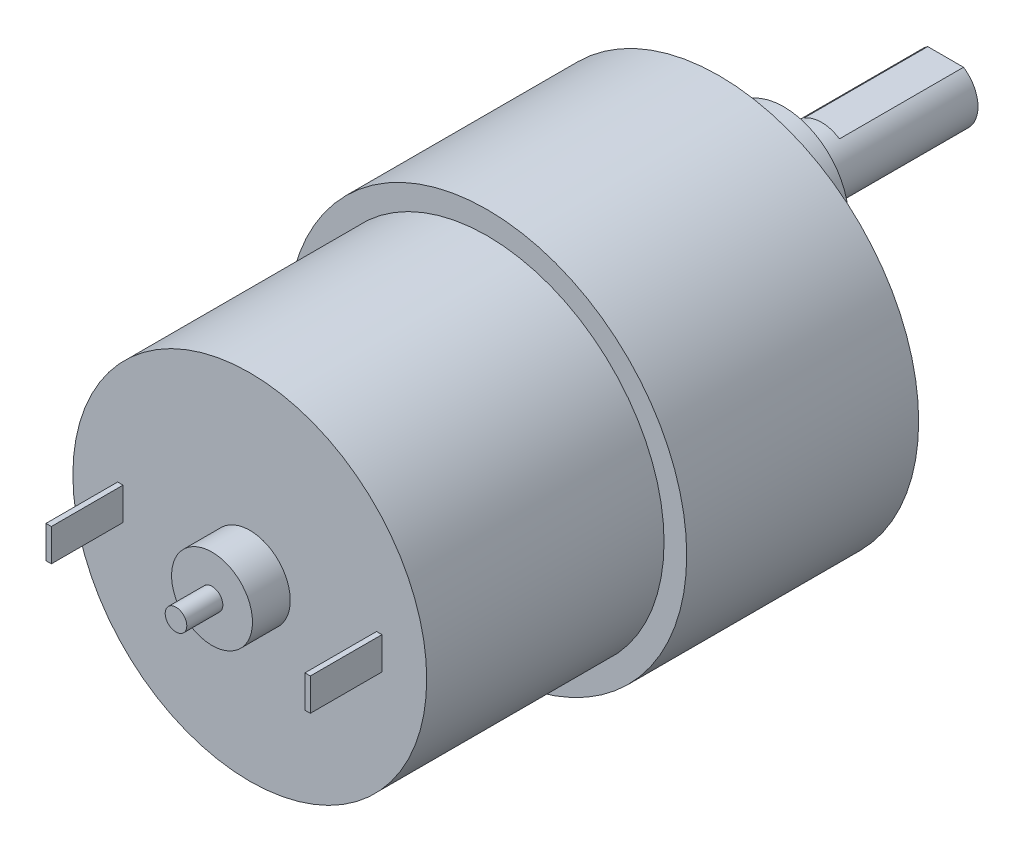
from build123d import *

# Parameters (mm, degrees)
SKETCH_1_R               = 18.5
EXTRUDE_1_DEPTH          = 21.5
SKETCH_2_R               = 6
EXTRUDE_2_DEPTH          = 6
SKETCH_3_R               = 3
EXTRUDE_3_DEPTH          = 15
CUT_EXTRUDE_1_DEPTH      = 1
CUT_EXTRUDE_1_DEPTH_BACK = 11.5
SKETCH_5_R               = 1.5
CUT_EXTRUDE_2_DEPTH      = 5
SKETCH_6_R               = 16.4
EXTRUDE_4_DEPTH          = 22
SKETCH_7_R               = 1
EXTRUDE_5_DEPTH          = 6.84
SKETCH_8_R               = 3.75
EXTRUDE_6_DEPTH          = 3.5
SKETCH_9_W               = 0.5
SKETCH_9_H               = 3
EXTRUDE_7_DEPTH          = 6.64


with BuildPart() as part:
    # 草图1 → 凸台-拉伸1 (new body)
    with BuildSketch(Plane.XY):
        Circle(SKETCH_1_R)
    extrude(amount=EXTRUDE_1_DEPTH)

    # 草图2 → 凸台-拉伸2 (add)
    with BuildSketch(Plane(origin=(0, 0, 0), x_dir=(-1, 0, 0), z_dir=(0, 0, -1))):
        with Locations((0, 7)):
            Circle(SKETCH_2_R)
    extrude(amount=EXTRUDE_2_DEPTH)

    # 草图3 → 凸台-拉伸3 (add)
    with BuildSketch(Plane(origin=(0, 0, -6), x_dir=(-1, 0, 0), z_dir=(0, 0, -1))):
        with Locations((0, 7)):
            Circle(SKETCH_3_R)
    extrude(amount=EXTRUDE_3_DEPTH)

    # 草图4 → 切除-拉伸1 (cut, two sides)
    with BuildSketch(Plane(origin=(0, 0, -21), x_dir=(-1, 0, 0), z_dir=(0, 0, -1))) as cut_extrude_1_sk:
        Polygon((-80.661429966, 9.5), (-1.658312395, 9.5), (1.658312395, 9.5), (80.661429966, 9.5), (80.661429966, 167.506235142), (-80.661429966, 167.506235142), align=None)
    extrude(amount=CUT_EXTRUDE_1_DEPTH, mode=Mode.SUBTRACT)
    extrude(cut_extrude_1_sk.sketch, amount=-CUT_EXTRUDE_1_DEPTH_BACK, mode=Mode.SUBTRACT)

    # 草图5 → 切除-拉伸2 (cut)
    with BuildSketch(Plane(origin=(0, 0, 0), x_dir=(-1, 0, 0), z_dir=(0, 0, -1))):
        with Locations((15.5, 0)):
            Circle(SKETCH_5_R)
        with Locations((7.75, -13.423393759)):
            Circle(SKETCH_5_R)
        with Locations((-7.75, -13.423393759)):
            Circle(SKETCH_5_R)
        with Locations((-15.5, 0)):
            Circle(SKETCH_5_R)
        with Locations((-7.75, 13.423393759)):
            Circle(SKETCH_5_R)
        with Locations((7.75, 13.423393759)):
            Circle(SKETCH_5_R)
    extrude(amount=-CUT_EXTRUDE_2_DEPTH, mode=Mode.SUBTRACT)

    # 草图6 → 凸台-拉伸4 (add)
    with BuildSketch(Plane.XY.offset(21.5)):
        Circle(SKETCH_6_R)
    extrude(amount=EXTRUDE_4_DEPTH)

    # 草图7 → 凸台-拉伸5 (add)
    with BuildSketch(Plane.XY.offset(43.5)):
        Circle(SKETCH_7_R)
    extrude(amount=EXTRUDE_5_DEPTH)

    # 草图8 → 凸台-拉伸6 (add)
    with BuildSketch(Plane.XY.offset(43.5)):
        Circle(SKETCH_8_R)
    extrude(amount=EXTRUDE_6_DEPTH)

    # 草图9 → 凸台-拉伸7 (add)
    with BuildSketch(Plane.XY.offset(43.5)):
        with Locations((-12, 0)):
            Rectangle(SKETCH_9_W, SKETCH_9_H)
        with Locations((12, 0)):
            Rectangle(SKETCH_9_W, SKETCH_9_H)
    extrude(amount=EXTRUDE_7_DEPTH)


solid = part.part
